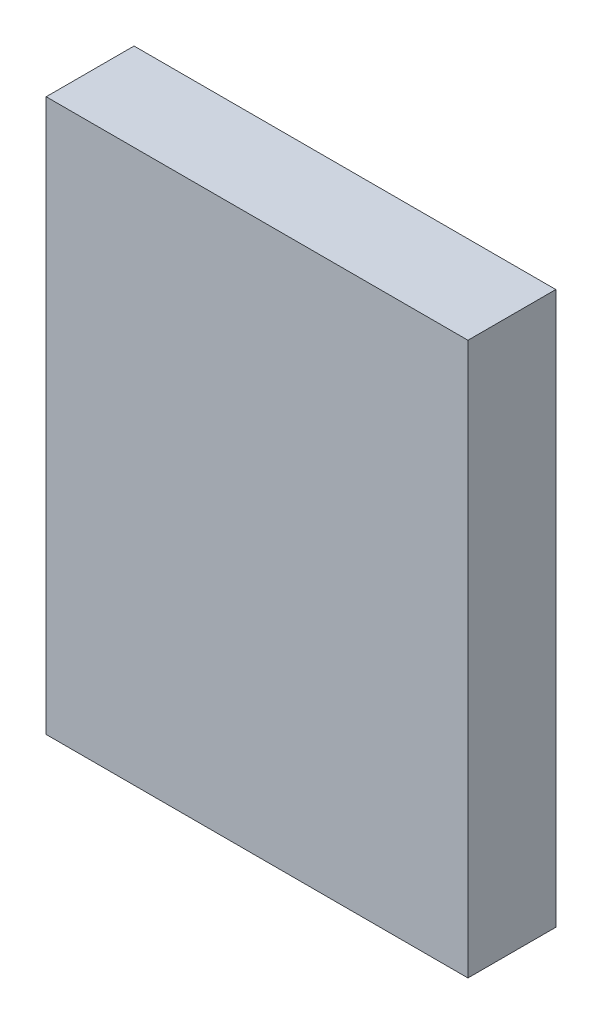
from build123d import *

# Parameters (mm, degrees)
SKETCH1_W           = 213.36
SKETCH1_H           = 279.4
BOSS_EXTRUDE1_DEPTH = 44.45


with BuildPart() as part:
    # Sketch1 → Boss-Extrude1 (new body)
    with BuildSketch(Plane.XY):
        with Locations((106.68, 139.7)):
            Rectangle(SKETCH1_W, SKETCH1_H)
    extrude(amount=BOSS_EXTRUDE1_DEPTH)


solid = part.part
